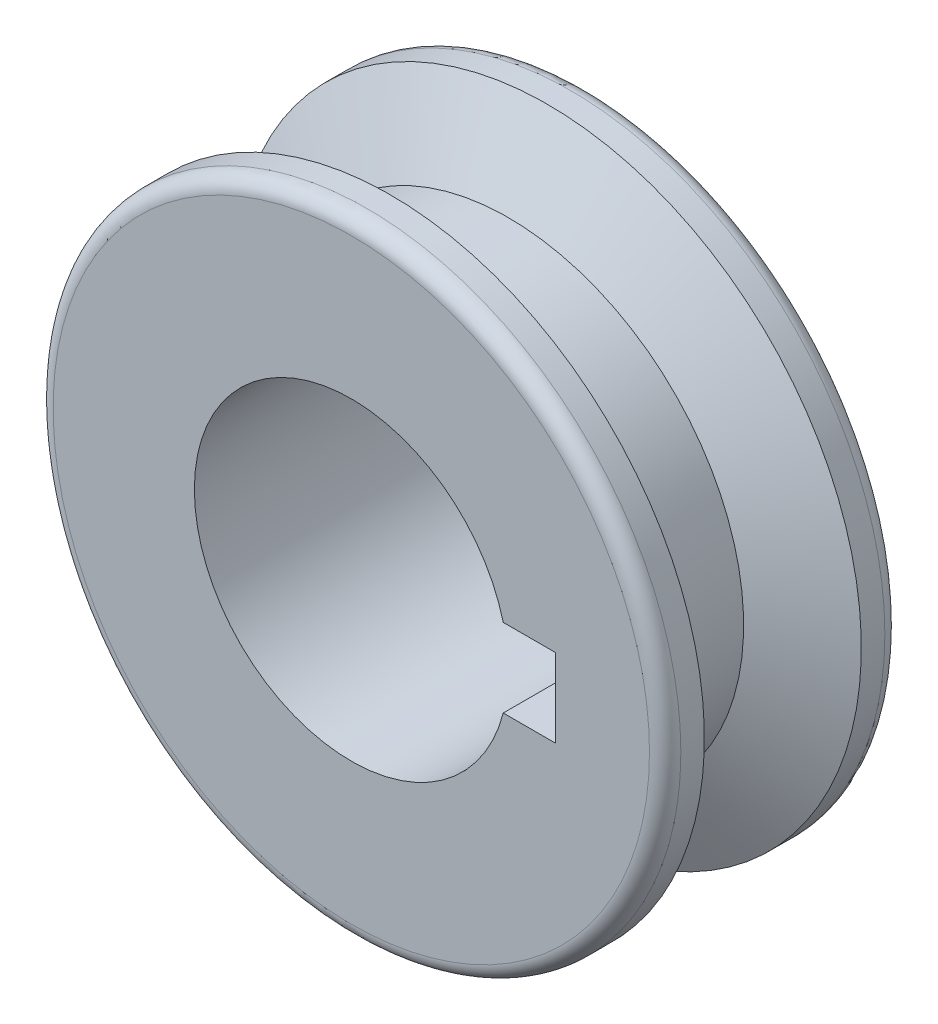
from build123d import *

# Parameters (mm, degrees)
SKETCH_1_R               = 20
SKETCH_1_R_2             = 10
EXTRUDE_1_DEPTH          = 15
CUT_EXTRUDE_1_DEPTH      = 3
CUT_EXTRUDE_1_DEPTH_BACK = 10
FILLET_1_R               = 1


with BuildPart() as part:
    # 草图1 → 凸台-拉伸1 (new body)
    with BuildSketch(Plane.XY):
        Circle(SKETCH_1_R)
        Circle(SKETCH_1_R_2, mode=Mode.SUBTRACT)
    extrude(amount=EXTRUDE_1_DEPTH)

    # 草图2 → 切除-旋转1 (revolve, cut)
    with BuildSketch(Plane(origin=(0, 0, 0), x_dir=(0, 0, -1), z_dir=(1, 0, 0))):
        Polygon((-5, 15), (-2.5, 20), (-12.5, 20), (-10, 15), align=None)
    revolve(axis=Axis((0, 0, -0.75), (0, 0, 1)), mode=Mode.SUBTRACT)

    # 草图3 → 切除-拉伸1 (cut, two sides)
    with BuildSketch(Plane(origin=(10, 0, 0), x_dir=(0, 0, -1), z_dir=(1, 0, 0))) as cut_extrude_1_sk:
        with BuildLine():
            Line((-15.73557603, 2.5), (0, 2.5))
            ThreePointArc((0, 2.5), (2.5, 0), (0, -2.5))
            Line((0, -2.5), (-15.73557603, -2.5))
            ThreePointArc((-15.73557603, -2.5), (-18.23557603, 0), (-15.73557603, 2.5))
        make_face()
    extrude(amount=CUT_EXTRUDE_1_DEPTH, mode=Mode.SUBTRACT)
    extrude(cut_extrude_1_sk.sketch, amount=-CUT_EXTRUDE_1_DEPTH_BACK, mode=Mode.SUBTRACT)

    # 圆角1
    fillet_1_edges = [part.edges().sort_by_distance(p)[0] for p in [
        (-20, 0, 0),
        (-20, 0, 15),
    ]]
    fillet(fillet_1_edges, radius=FILLET_1_R)


solid = part.part
